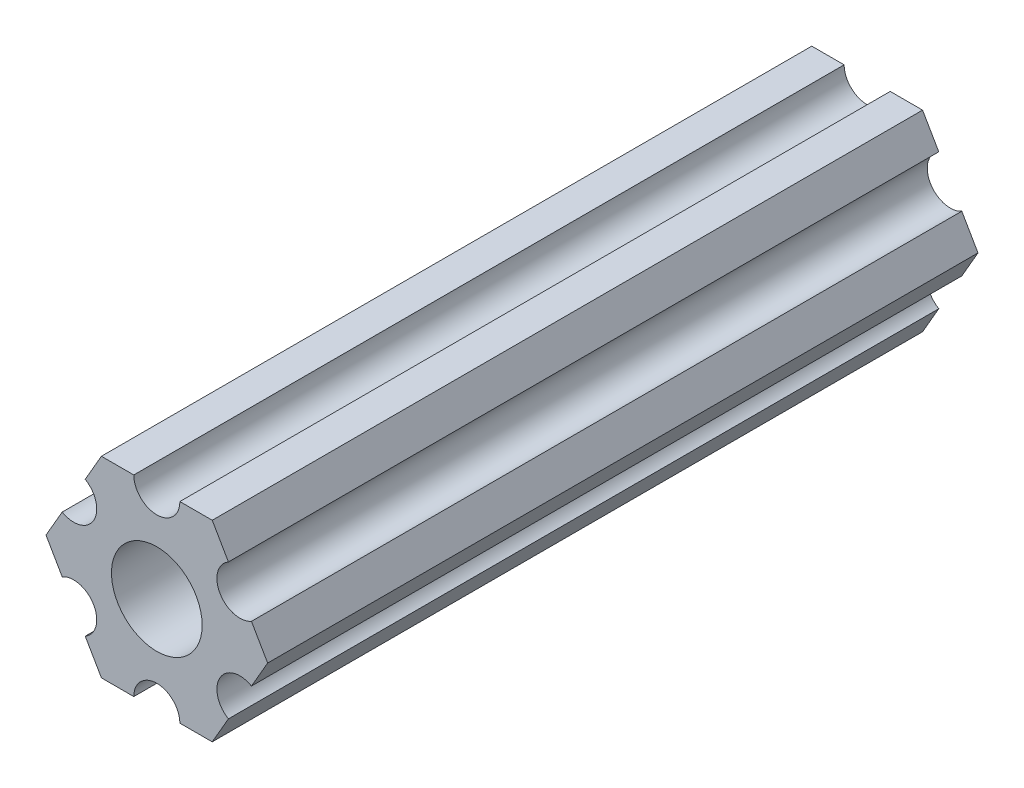
from build123d import *

# Parameters (mm, degrees)
ESBO_O1_R                = 3
RESSALTO_EXTRUS_O1_DEPTH = 47


with BuildPart() as part:
    # Esboço1 → Ressalto-extrusão1 (new body)
    with BuildSketch(Plane.XY):
        with BuildLine():
            Line((4.737261314, 4.494822715), (3.666174209, 6.35))
            Line((3.666174209, 6.35), (1.524, 6.35))
            ThreePointArc((1.524, 6.35), (0, 4.826), (-1.524, 6.35))
            Line((-1.524, 6.35), (-3.666174209, 6.35))
            Line((-3.666174209, 6.35), (-4.737261314, 4.494822715))
            ThreePointArc((-4.737261314, 4.494822715), (-4.179438599, 3.937), (-3.975261314, 3.175))
            ThreePointArc((-3.975261314, 3.175), (-4.737261314, 1.855177285), (-6.261261314, 1.855177285))
            Line((-6.261261314, 1.855177285), (-7.332348419, 0))
            Line((-7.332348419, 0), (-6.261261314, -1.855177285))
            ThreePointArc((-6.261261314, -1.855177285), (-4.737261314, -1.855177285), (-3.975261314, -3.175))
            ThreePointArc((-3.975261314, -3.175), (-4.179438599, -3.937), (-4.737261314, -4.494822715))
            Line((-4.737261314, -4.494822715), (-3.666174209, -6.35))
            Line((-3.666174209, -6.35), (-1.524, -6.35))
            ThreePointArc((-1.524, -6.35), (0, -4.826), (1.524, -6.35))
            Line((1.524, -6.35), (3.666174209, -6.35))
            Line((3.666174209, -6.35), (4.737261314, -4.494822715))
            ThreePointArc((4.737261314, -4.494822715), (4.179438599, -2.413), (6.261261314, -1.855177285))
            Line((6.261261314, -1.855177285), (7.332348419, 0))
            Line((7.332348419, 0), (6.261261314, 1.855177285))
            ThreePointArc((6.261261314, 1.855177285), (4.179438599, 2.413), (4.737261314, 4.494822715))
        make_face()
        Circle(ESBO_O1_R, mode=Mode.SUBTRACT)
    extrude(amount=RESSALTO_EXTRUS_O1_DEPTH)


solid = part.part
